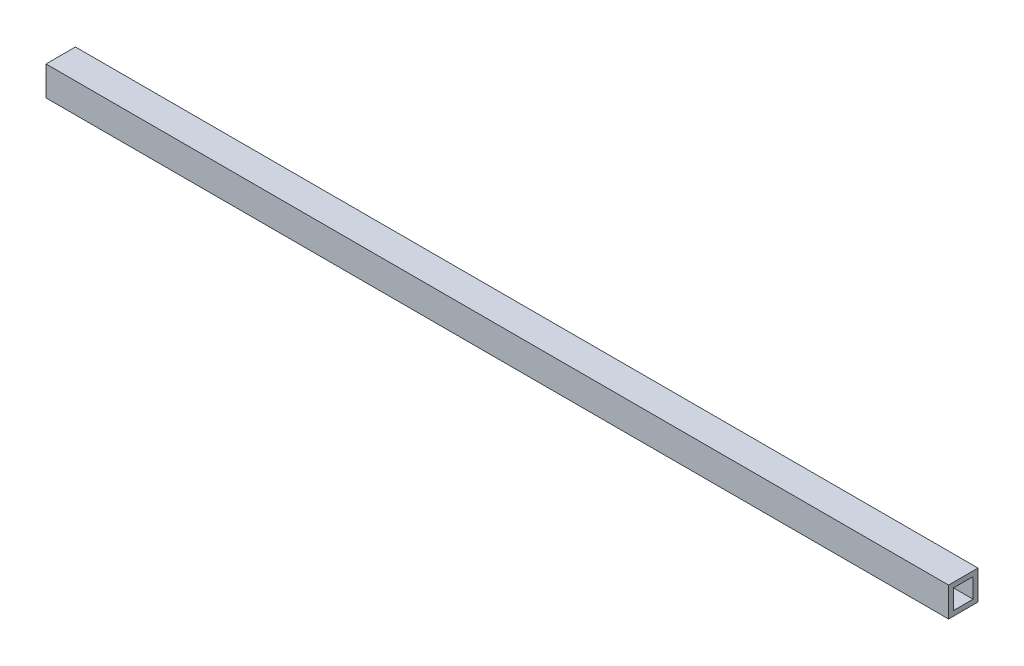
from build123d import *

# Parameters (mm, degrees)
SKETCH1_W           = 19.05
SKETCH1_H           = 19.05
SKETCH1_W_2         = 12.7
SKETCH1_H_2         = 12.7
EXTRUDE_THIN1_DEPTH = 584.2


with BuildPart() as part:
    # Sketch1 → Extrude-Thin1 (new body)
    with BuildSketch(Plane(origin=(0, 0, 0), x_dir=(0, 0, -1), z_dir=(1, 0, 0))):
        with Locations((6.35, 6.35)):
            Rectangle(SKETCH1_W, SKETCH1_H)
        with Locations((6.35, 6.35)):
            Rectangle(SKETCH1_W_2, SKETCH1_H_2, mode=Mode.SUBTRACT)
    extrude(amount=EXTRUDE_THIN1_DEPTH)


solid = part.part
